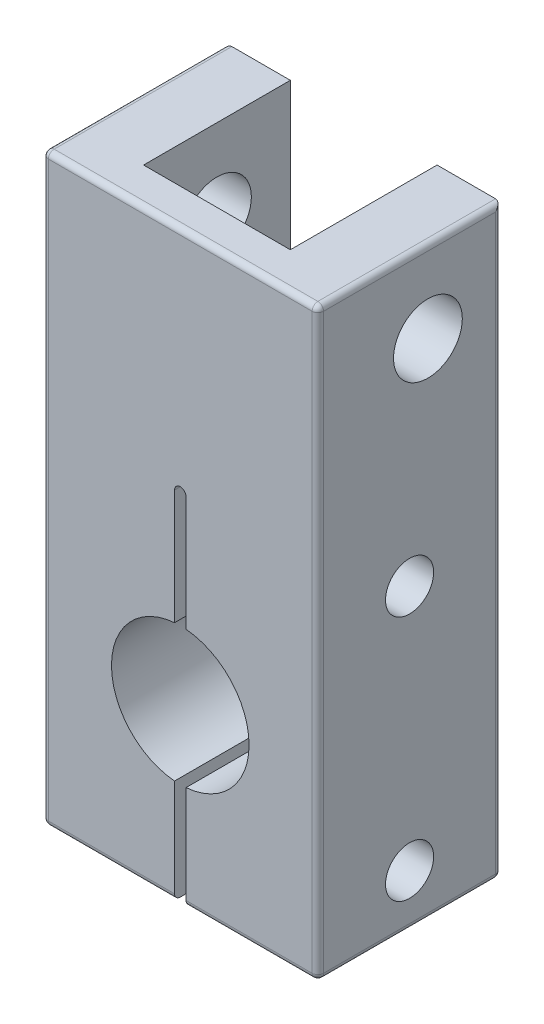
from build123d import *

# Parameters (mm, degrees)
ESQUISSE1_R             = 6
BOSS_EXTRU_1_DEPTH      = 16
ENL_V_START             = -16
ENL_V_MAT_EXTRU_1_DEPTH = 16
ESQUISSE4_R             = 2.1
ENL_V_MAT_EXTRU_2_DEPTH = 25
ESQUISSE6_W             = 12.8
ESQUISSE6_H             = 12.8
ENL_V_MAT_EXTRU_3_DEPTH = 15
ESQUISSE7_R             = 3
ENL_V_MAT_EXTRU_5_DEPTH = 25
CONG_1_R                = 0.5


with BuildPart() as part:
    # Esquisse1 → Boss.-Extru.1 (new body)
    with BuildSketch(Plane.XY):
        Polygon((0, 0), (24, 0), (24, 24), (24, 51), (0, 51), (0, 30), align=None)
        with Locations((12, 15)):
            Circle(ESQUISSE1_R, mode=Mode.SUBTRACT)
    extrude(amount=BOSS_EXTRU_1_DEPTH)

    # Esquisse2 → Enlèv. mat.-Extru.1 (cut)
    with BuildSketch(Plane(origin=(0, 0, 0), x_dir=(-1, 0, 0), z_dir=(0, 0, -1)).offset(ENL_V_START)):
        with BuildLine():
            Line((-11.5, 31), (-11.5, -14))
            ThreePointArc((-11.5, -14), (-12, -14.5), (-12.5, -14))
            Line((-12.5, -14), (-12.5, 31))
            ThreePointArc((-12.5, 31), (-12, 31.5), (-11.5, 31))
        make_face()
    extrude(amount=ENL_V_MAT_EXTRU_1_DEPTH, mode=Mode.SUBTRACT)

    # Esquisse4 → Enlèv. mat.-Extru.2 (cut, through all)
    with BuildSketch(Plane(origin=(24, 0, 0), x_dir=(0, 0, -1), z_dir=(1, 0, 0))):
        with Locations((-8, 25.989565186)):
            Circle(ESQUISSE4_R)
        with Locations((-8, 4.510434814)):
            Circle(ESQUISSE4_R)
    extrude(amount=-ENL_V_MAT_EXTRU_2_DEPTH, mode=Mode.SUBTRACT)

    # Esquisse6 → Enlèv. mat.-Extru.3 (cut)
    with BuildSketch(Plane(origin=(0, 51, 0), x_dir=(1, 0, 0), z_dir=(0, 1, 0))):
        with Locations((12, -6.4)):
            Rectangle(ESQUISSE6_W, ESQUISSE6_H)
    extrude(amount=-ENL_V_MAT_EXTRU_3_DEPTH, mode=Mode.SUBTRACT)

    # Esquisse7 → Enlèv. mat.-Extru.5 (cut, through all)
    with BuildSketch(Plane(origin=(24, 0, 0), x_dir=(0, 0, -1), z_dir=(1, 0, 0))):
        with Locations((-6.4, 43.9)):
            Circle(ESQUISSE7_R)
    extrude(amount=-ENL_V_MAT_EXTRU_5_DEPTH, mode=Mode.SUBTRACT)

    # Congé1
    cong_1_edges = [part.edges().sort_by_distance(p)[0] for p in [
        (24, 25.5, 16),
        (0, 51, 8),
        (24, 51, 8),
        (24, 0, 8),
        (0, 0, 8),
        (12, 51, 16),
        (18.25, 0, 0),
        (18.25, 0, 16),
        (0, 25.5, 16),
        (0, 25.5, 0),
        (24, 25.5, 0),
        (5.75, 0, 16),
        (5.75, 0, 0),
    ]]
    fillet(cong_1_edges, radius=CONG_1_R)


solid = part.part
